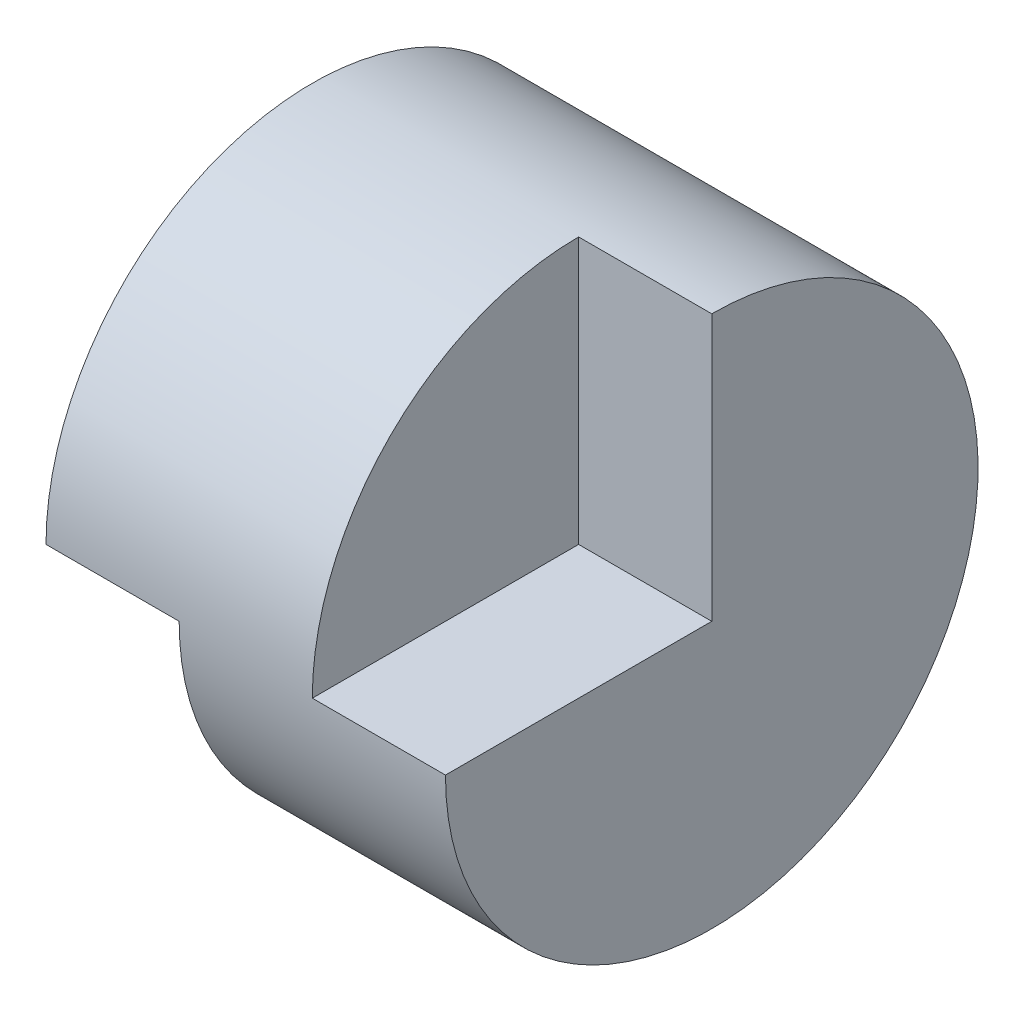
from build123d import *

# Parameters (mm, degrees)
SKETCH1_W           = 40
SKETCH1_H           = 40
BOSS_EXTRUDE1_DEPTH = 40
SKETCH2_W           = 10
SKETCH2_H           = 20
CUT_EXTRUDE1_DEPTH  = 40
CUT_EXTRUDE2_DEPTH  = 40
CUT_EXTRUDE3_DEPTH  = 40
CUT_EXTRUDE4_DEPTH  = 10
CUT_EXTRUDE5_DEPTH  = 20


with BuildPart() as part:
    # Sketch1 → Boss-Extrude1 (new body)
    with BuildSketch(Plane.XY):
        with Locations((20, 20)):
            Rectangle(SKETCH1_W, SKETCH1_H)
    extrude(amount=BOSS_EXTRUDE1_DEPTH)

    # Sketch2 → Cut-Extrude1 (cut)
    with BuildSketch(Plane.XY.offset(40)):
        with Locations((5, 30)):
            Rectangle(SKETCH2_W, SKETCH2_H)
    extrude(amount=-CUT_EXTRUDE1_DEPTH, mode=Mode.SUBTRACT)

    # Sketch3 → Cut-Extrude2 (cut)
    with BuildSketch(Plane.ZY.offset(-10)):
        with BuildLine():
            Line((40, 40), (20, 40))
            ThreePointArc((20, 40), (34.142135624, 34.142135624), (40, 20))
            Line((40, 20), (40, 40))
        make_face()
        with BuildLine():
            Line((0, 40), (0, 20))
            ThreePointArc((0, 20), (5.857864376, 34.142135624), (20, 40))
            Line((20, 40), (0, 40))
        make_face()
    extrude(amount=-CUT_EXTRUDE2_DEPTH, mode=Mode.SUBTRACT)

    # Sketch4 → Cut-Extrude3 (cut)
    with BuildSketch(Plane.ZY):
        with BuildLine():
            ThreePointArc((20, 0), (5.857864376, 5.857864376), (0, 20))
            Line((0, 20), (0, 0))
            Line((0, 0), (20, 0))
        make_face()
        with BuildLine():
            ThreePointArc((40, 20), (34.142135624, 5.857864376), (20, 0))
            Line((20, 0), (40, 0))
            Line((40, 0), (40, 20))
        make_face()
    extrude(amount=-CUT_EXTRUDE3_DEPTH, mode=Mode.SUBTRACT)

    # Sketch5 → Cut-Extrude4 (cut)
    with BuildSketch(Plane(origin=(40, 0, 0), x_dir=(0, 0, -1), z_dir=(1, 0, 0))):
        with BuildLine():
            Line((-40, 20), (-20, 20))
            Line((-20, 20), (-20, 40))
            ThreePointArc((-20, 40), (-34.142135624, 34.142135624), (-40, 20))
        make_face()
    extrude(amount=-CUT_EXTRUDE4_DEPTH, mode=Mode.SUBTRACT)

    # Sketch6 → Cut-Extrude5 (cut)
    with BuildSketch(Plane.ZY):
        with BuildLine():
            Line((20, 0), (20, 20))
            Line((20, 20), (40, 20))
            ThreePointArc((40, 20), (34.142135624, 5.857864376), (20, 0))
        make_face()
    extrude(amount=-CUT_EXTRUDE5_DEPTH, mode=Mode.SUBTRACT)


solid = part.part
